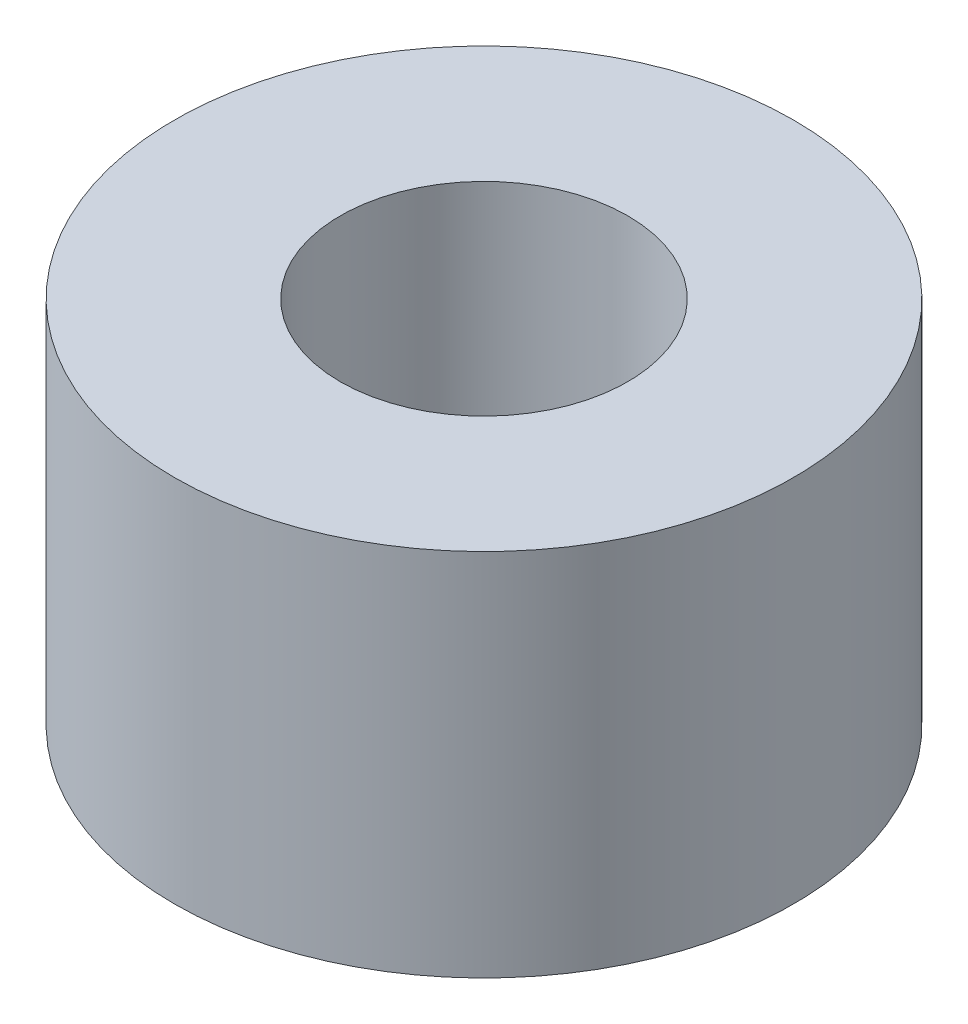
from build123d import *

# Parameters (mm, degrees)
SKETCH1_R           = 3.5
SKETCH1_R_2         = 1.625
BOSS_EXTRUDE1_DEPTH = 2.0875


with BuildPart() as part:
    # Sketch1 → Boss-Extrude1 (new body, symmetric)
    with BuildSketch(Plane(origin=(0, 0, 0), x_dir=(1, 0, 0), z_dir=(0, 1, 0))):
        Circle(SKETCH1_R)
        Circle(SKETCH1_R_2, mode=Mode.SUBTRACT)
    extrude(amount=BOSS_EXTRUDE1_DEPTH, both=True)


solid = part.part
